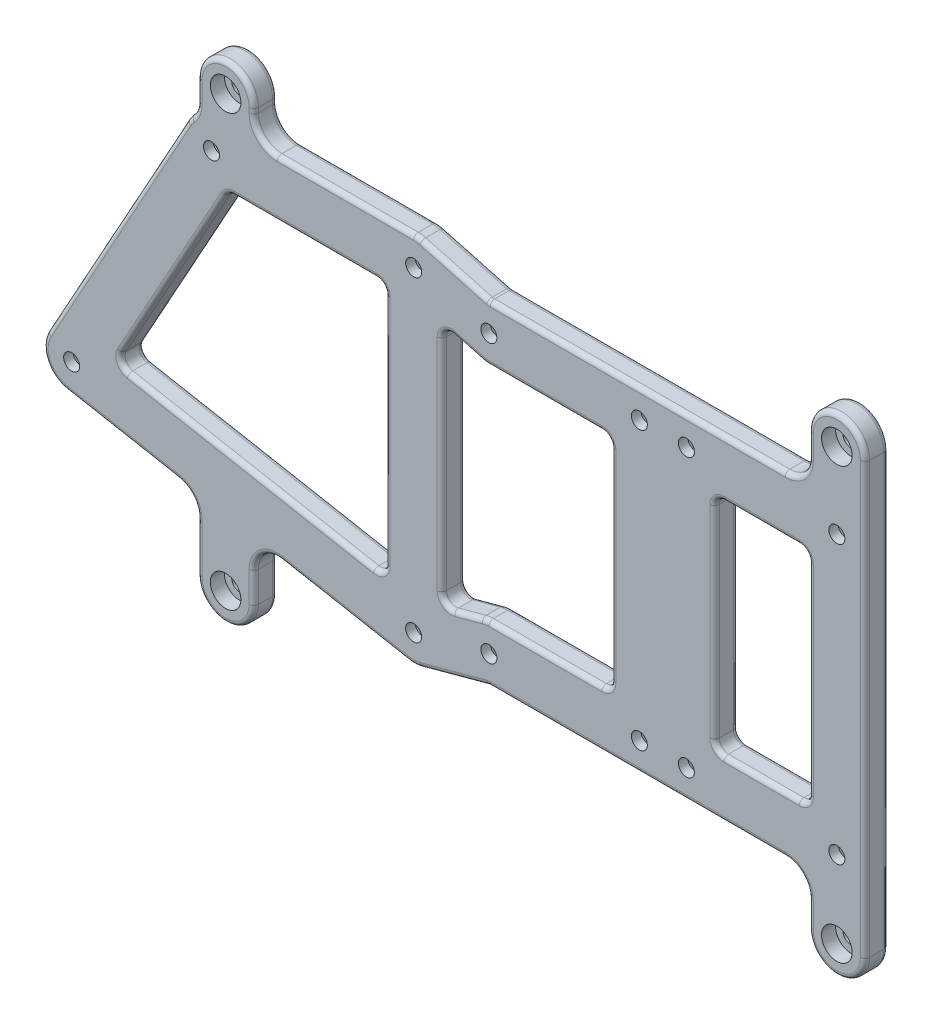
from build123d import *

# Parameters (mm, degrees)
ESQUISSE1_R             = 1.7
BOSS_EXTRU_2_DEPTH      = 5
ESQUISSE2_R             = 1.7
ESQUISSE2_W             = 20
ESQUISSE2_H             = 47
BOSS_EXTRU_3_DEPTH      = 5
CONG_1_R                = 2
ESQUISSE4_R             = 1.7
BOSS_EXTRU_4_DEPTH      = 5
ENL_V_MAT_EXTRU_1_DEPTH = 3
CONG_2_R                = 5
ESQUISSE5_R             = 3.25
ENL_V_MAT_EXTRU_2_DEPTH = 3
CONG_3_R                = 1


with BuildPart() as part:
    # Esquisse1 → Boss.-Extru.2 (new body)
    with BuildSketch(Plane.XY):
        with BuildLine():
            Line((-1.094858784, -39.52426133), (-73.834858784, -26.02426133))
            ThreePointArc((-73.834858784, -26.02426133), (-78.166058346, -22.685837915), (-77.989957766, -17.220186159))
            Line((-77.989957766, -17.220186159), (-48.249957766, 36.529813841))
            ThreePointArc((-48.249957766, 36.529813841), (-46.047221435, 38.793601506), (-43, 39.625))
            Line((-43, 39.625), (0, 39.625))
            ThreePointArc((0, 39.625), (4.242640687, 37.867640687), (6, 33.625))
            Line((6, 33.625), (6, -33.625))
            ThreePointArc((6, -33.625), (3.836068775, -38.238521036), (-1.094858784, -39.52426133))
        make_face()
        with Locations((-43, 33.625)):
            Circle(ESQUISSE1_R, mode=Mode.SUBTRACT)
        with Locations((0, 33.625)):
            Circle(ESQUISSE1_R, mode=Mode.SUBTRACT)
        with Locations((0, -33.625)):
            Circle(ESQUISSE1_R, mode=Mode.SUBTRACT)
        with Locations((-72.74, -20.125)):
            Circle(ESQUISSE1_R, mode=Mode.SUBTRACT)
        Polygon((-39.462615933, 27.625), (-6, 27.625), (-6, -26.40898594), (-63.45931901, -15.744966052), align=None, mode=Mode.SUBTRACT)
    extrude(amount=BOSS_EXTRU_2_DEPTH)

    # Esquisse2 → Boss.-Extru.3 (add)
    with BuildSketch(Plane.XY.offset(5)):
        with BuildLine():
            Line((16, 35.5), (90, 35.5))
            ThreePointArc((90, 35.5), (94.242640687, 33.742640687), (96, 29.5))
            Line((96, 29.5), (96, -29.5))
            ThreePointArc((96, -29.5), (94.242640687, -33.742640687), (90, -35.5))
            Line((90, -35.5), (16, -35.5))
            Line((16, -35.5), (1.571418144, -39.415565173))
            ThreePointArc((1.571418144, -39.415565173), (4.76594738, -37.269961669), (6, -33.625))
            Line((6, -33.625), (6, -25.996746353))
            Line((6, -25.996746353), (14.428581856, -23.709434827))
            ThreePointArc((14.428581856, -23.709434827), (15.207343402, -23.552589175), (16, -23.5))
            Line((16, -23.5), (42, -23.5))
            Line((42, -23.5), (42, 23.5))
            Line((42, 23.5), (16, 23.5))
            ThreePointArc((16, 23.5), (15.207343402, 23.552589175), (14.428581856, 23.709434827))
            Line((14.428581856, 23.709434827), (6, 25.996746353))
            Line((6, 25.996746353), (6, 33.625))
            ThreePointArc((6, 33.625), (4.76594738, 37.269961669), (1.571418144, 39.415565173))
            Line((1.571418144, 39.415565173), (16, 35.5))
        make_face()
        with Locations((16, 29.5)):
            Circle(ESQUISSE2_R, mode=Mode.SUBTRACT)
        with Locations((48, 29.5)):
            Circle(ESQUISSE2_R, mode=Mode.SUBTRACT)
        with Locations((48, -29.5)):
            Circle(ESQUISSE2_R, mode=Mode.SUBTRACT)
        with Locations((16, -29.5)):
            Circle(ESQUISSE2_R, mode=Mode.SUBTRACT)
        with Locations((58, 29.5)):
            Circle(ESQUISSE2_R, mode=Mode.SUBTRACT)
        with Locations((90, 29.5)):
            Circle(ESQUISSE2_R, mode=Mode.SUBTRACT)
        with Locations((90, -29.5)):
            Circle(ESQUISSE2_R, mode=Mode.SUBTRACT)
        with Locations((58, -29.5)):
            Circle(ESQUISSE2_R, mode=Mode.SUBTRACT)
        with Locations((74, 0)):
            Rectangle(ESQUISSE2_W, ESQUISSE2_H, mode=Mode.SUBTRACT)
    extrude(amount=-BOSS_EXTRU_3_DEPTH)

    # Congé1
    cong_1_edges = [part.edges().sort_by_distance(p)[0] for p in [
        (-63.45931901, -15.744966052, 2.5),
        (-6, -26.40898594, 2.5),
        (-6, 27.625, 2.5),
        (-39.462615933, 27.625, 2.5),
        (16, 35.5, 2.5),
        (16, -35.5, 2.5),
        (6, -25.996746353, 2.5),
        (42, -23.5, 2.5),
        (42, 23.5, 2.5),
        (6, 25.996746353, 2.5),
        (64, 23.5, 2.5),
        (84, 23.5, 2.5),
        (84, -23.5, 2.5),
        (64, -23.5, 2.5),
    ]]
    fillet(cong_1_edges, radius=CONG_1_R)

    # Esquisse4 → Boss.-Extru.4 (add)
    with BuildSketch(Plane.XY.offset(5)):
        with BuildLine():
            Line((96, 45.625), (96, 29.5))
            Line((96, 29.5), (84, 35.5))
            Line((84, 35.5), (84, 45.625))
            ThreePointArc((84, 45.625), (90, 51.625), (96, 45.625))
        make_face()
        with Locations((90, 45.625)):
            Circle(ESQUISSE4_R, mode=Mode.SUBTRACT)
        with BuildLine():
            Line((96, -45.917313208), (96, -29.5))
            Line((96, -29.5), (84, -35.5))
            Line((84, -35.5), (84, -45.917313208))
            ThreePointArc((84, -45.917313208), (90, -51.917313208), (96, -45.917313208))
        make_face()
        with Locations((90, -45.917313208)):
            Circle(ESQUISSE4_R, mode=Mode.SUBTRACT)
        with BuildLine():
            Line((-34, 45.625), (-34, 39.625))
            Line((-34, 39.625), (-46, 38.821152423))
            Line((-46, 38.821152423), (-46, 45.625))
            ThreePointArc((-46, 45.625), (-40, 51.625), (-34, 45.625))
        make_face()
        with Locations((-40, 45.625)):
            Circle(ESQUISSE4_R, mode=Mode.SUBTRACT)
        with BuildLine():
            Line((-34, -45.917313208), (-34, -33.417313208))
            Line((-34, -33.417313208), (-46, -31.190202952))
            Line((-46, -31.190202952), (-46, -45.917313208))
            ThreePointArc((-46, -45.917313208), (-40, -51.917313208), (-34, -45.917313208))
        make_face()
        with Locations((-40, -45.917313208)):
            Circle(ESQUISSE4_R, mode=Mode.SUBTRACT)
    extrude(amount=-BOSS_EXTRU_4_DEPTH)

    # Esquisse3 → Enlèv. mat.-Extru.1 (cut)
    with BuildSketch(Plane(origin=(0, 0, 0), x_dir=(-1, 0, 0), z_dir=(0, 0, -1))):
        Polygon((-91.645448267, -26.65), (-88.354551733, -26.65), (-86.709103466, -29.5), (-88.354551733, -32.35), (-91.645448267, -32.35), (-93.290896534, -29.5), align=None)
        Polygon((-91.645448267, 32.35), (-88.354551733, 32.35), (-86.709103466, 29.5), (-88.354551733, 26.65), (-91.645448267, 26.65), (-93.290896534, 29.5), align=None)
        Polygon((-59.645448267, 32.35), (-56.354551733, 32.35), (-54.709103466, 29.5), (-56.354551733, 26.65), (-59.645448267, 26.65), (-61.290896534, 29.5), align=None)
        Polygon((-49.645448267, 32.35), (-46.354551733, 32.35), (-44.709103466, 29.5), (-46.354551733, 26.65), (-49.645448267, 26.65), (-51.290896534, 29.5), align=None)
        Polygon((-59.645448267, -26.65), (-56.354551733, -26.65), (-54.709103466, -29.5), (-56.354551733, -32.35), (-59.645448267, -32.35), (-61.290896534, -29.5), align=None)
        Polygon((-49.645448267, -26.65), (-46.354551733, -26.65), (-44.709103466, -29.5), (-46.354551733, -32.35), (-49.645448267, -32.35), (-51.290896534, -29.5), align=None)
        Polygon((-17.645448267, -26.65), (-14.354551733, -26.65), (-12.709103466, -29.5), (-14.354551733, -32.35), (-17.645448267, -32.35), (-19.290896534, -29.5), align=None)
        Polygon((-1.645448267, -30.775), (1.645448267, -30.775), (3.290896534, -33.625), (1.645448267, -36.475), (-1.645448267, -36.475), (-3.290896534, -33.625), align=None)
        Polygon((-17.645448267, 32.35), (-14.354551733, 32.35), (-12.709103466, 29.5), (-14.354551733, 26.65), (-17.645448267, 26.65), (-19.290896534, 29.5), align=None)
        Polygon((-1.645448267, 36.475), (1.645448267, 36.475), (3.290896534, 33.625), (1.645448267, 30.775), (-1.645448267, 30.775), (-3.290896534, 33.625), align=None)
        Polygon((41.354551733, 36.475), (44.645448267, 36.475), (46.290896534, 33.625), (44.645448267, 30.775), (41.354551733, 30.775), (39.709103466, 33.625), align=None)
        Polygon((71.094551733, -17.275), (74.385448267, -17.275), (76.030896534, -20.125), (74.385448267, -22.975), (71.094551733, -22.975), (69.449103466, -20.125), align=None)
    extrude(amount=-ENL_V_MAT_EXTRU_1_DEPTH, mode=Mode.SUBTRACT)

    # Congé2
    cong_2_edges = [part.edges().sort_by_distance(p)[0] for p in [
        (84, -35.5, 2.5),
        (-34, 39.625, 2.5),
        (-46, 38.821152423, 2.5),
        (-46, -31.190202952, 2.5),
        (-34, -33.417313208, 2.5),
        (84, 35.5, 2.5),
    ]]
    fillet(cong_2_edges, radius=CONG_2_R)

    # Esquisse5 → Enlèv. mat.-Extru.2 (cut)
    with BuildSketch(Plane.XY.offset(5)):
        with Locations((-40, 45.625)):
            Circle(ESQUISSE5_R)
        with Locations((-40, -45.917313208)):
            Circle(ESQUISSE5_R)
        with Locations((90, -45.917313208)):
            Circle(ESQUISSE5_R)
        with Locations((90, 45.625)):
            Circle(ESQUISSE5_R)
    extrude(amount=-ENL_V_MAT_EXTRU_2_DEPTH, mode=Mode.SUBTRACT)

    # Congé3
    cong_3_edges = [part.edges().sort_by_distance(p)[0] for p in [
        (-61.961238232, -28.227916506, 0),
        (-78.166058346, -22.685837915, 0),
        (-63.119957766, 9.654813841, 0),
        (8.657083641, 37.492688391, 0),
        (8.657083641, 37.492688391, 5),
        (74, -23.5, 0),
        (74, -23.5, 5),
        (-78.166058346, -22.685837915, 5),
        (64, 0, 0),
        (64, 0, 5),
        (47.633277593, -35.5, 0),
        (47.633277593, -35.5, 5),
        (74, 23.5, 0),
        (74, 23.5, 5),
        (84, 0, 0),
        (84, 0, 5),
        (42, 0, 0),
        (42, 0, 5),
        (28, -23.5, 0),
        (28, -23.5, 5),
        (6, 0, 5),
        (6, 0, 0),
        (11.476193952, 24.51064089, 0),
        (11.476193952, 24.51064089, 5),
        (-34.547832268, -21.110721771, 0),
        (-34.547832268, -21.110721771, 5),
        (-6, 0.81067604, 0),
        (-6, 0.81067604, 5),
        (-23.141743956, 27.625, 0),
        (-23.141743956, 27.625, 5),
        (-51.074609218, 6.638293913, 0),
        (-51.074609218, 6.638293913, 5),
        (16.00233632, 35.517529725, 5),
        (16.00233632, 35.517529725, 0),
        (64.585786438, -22.914213562, 5),
        (64.585786438, -22.914213562, 0),
        (16.00233632, -35.517529725, 5),
        (16.00233632, -35.517529725, 0),
        (64.585786438, 22.914213562, 5),
        (64.585786438, 22.914213562, 0),
        (83.414213562, 22.914213562, 5),
        (83.414213562, 22.914213562, 0),
        (83.414213562, -22.914213562, 5),
        (83.414213562, -22.914213562, 0),
        (41.414213562, -22.914213562, 5),
        (41.414213562, -22.914213562, 0),
        (41.414213562, 22.914213562, 5),
        (41.414213562, 22.914213562, 0),
        (6.785012777, 24.970307688, 5),
        (6.785012777, 24.970307688, 0),
        (6.785012777, -24.970307688, 5),
        (-61.961238232, -28.227916506, 5),
        (6.785012777, -24.970307688, 0),
        (-6.721310408, -25.541488265, 0),
        (-6.721310408, -25.541488265, 5),
        (-6.585786438, 27.039213562, 0),
        (-6.585786438, 27.039213562, 5),
        (-62.174444796, -15.138567374, 0),
        (-62.174444796, -15.138567374, 5),
        (-39.29922839, 27.347867169, 0),
        (-39.29922839, 27.347867169, 5),
        (0.244399099, -39.620020357, 5),
        (90, -51.917313208, 0),
        (90, -51.917313208, 5),
        (-46, 43.399917218, 5),
        (-40, 51.625, 5),
        (-40, 51.625, 0),
        (-46, 43.399917218, 0),
        (-40, -51.917313208, 0),
        (-34, -42.673985733, 0),
        (-40, -51.917313208, 5),
        (-34, -42.673985733, 5),
        (90, 51.625, 0),
        (84, 43.0625, 0),
        (90, 51.625, 5),
        (84, 43.0625, 5),
        (-14.5, 39.625, 5),
        (-46, -40.632467999, 0),
        (-46, -40.632467999, 5),
        (-14.591238232, -37.01943424, 5),
        (-14.591238232, -37.01943424, 0),
        (84, -43.208656604, 0),
        (84, -43.208656604, 5),
        (47.633277593, 35.5, 0),
        (47.633277593, 35.5, 5),
        (-47.844926078, 37.164306613, 5),
        (-47.844926078, 37.164306613, 0),
        (-34, 45.125, 0),
        (-34, 45.125, 5),
        (-47.155399136, -32.15089881, 5),
        (-47.155399136, -32.15089881, 0),
        (-32.196723979, -35.586057395, 5),
        (-32.196723979, -35.586057395, 0),
        (82.535533906, -36.964466094, 5),
        (82.535533906, -36.964466094, 0),
        (82.535533906, 36.964466094, 5),
        (82.535533906, 36.964466094, 0),
        (-46.353398114, 39.328462071, 5),
        (-46.353398114, 39.328462071, 0),
        (-32.535533906, 41.089466094, 5),
        (-32.535533906, 41.089466094, 0),
        (0.792656598, 39.572410825, 0),
        (0.792656598, 39.572410825, 5),
        (96, -0.146156604, 0),
        (8.657083641, -37.492688391, 0),
        (11.476193952, -24.51064089, 0),
        (15.207343402, -23.552589175, 0),
        (28, 23.5, 0),
        (15.207343402, 23.552589175, 0),
        (15.207343402, 23.552589175, 5),
        (28, 23.5, 5),
        (15.207343402, -23.552589175, 5),
        (11.476193952, -24.51064089, 5),
        (8.657083641, -37.492688391, 5),
        (96, -0.146156604, 5),
        (-14.5, 39.625, 0),
        (-63.119957766, 9.654813841, 5),
        (0.244399099, -39.620020357, 0),
    ]]
    fillet(cong_3_edges, radius=CONG_3_R)


solid = part.part
